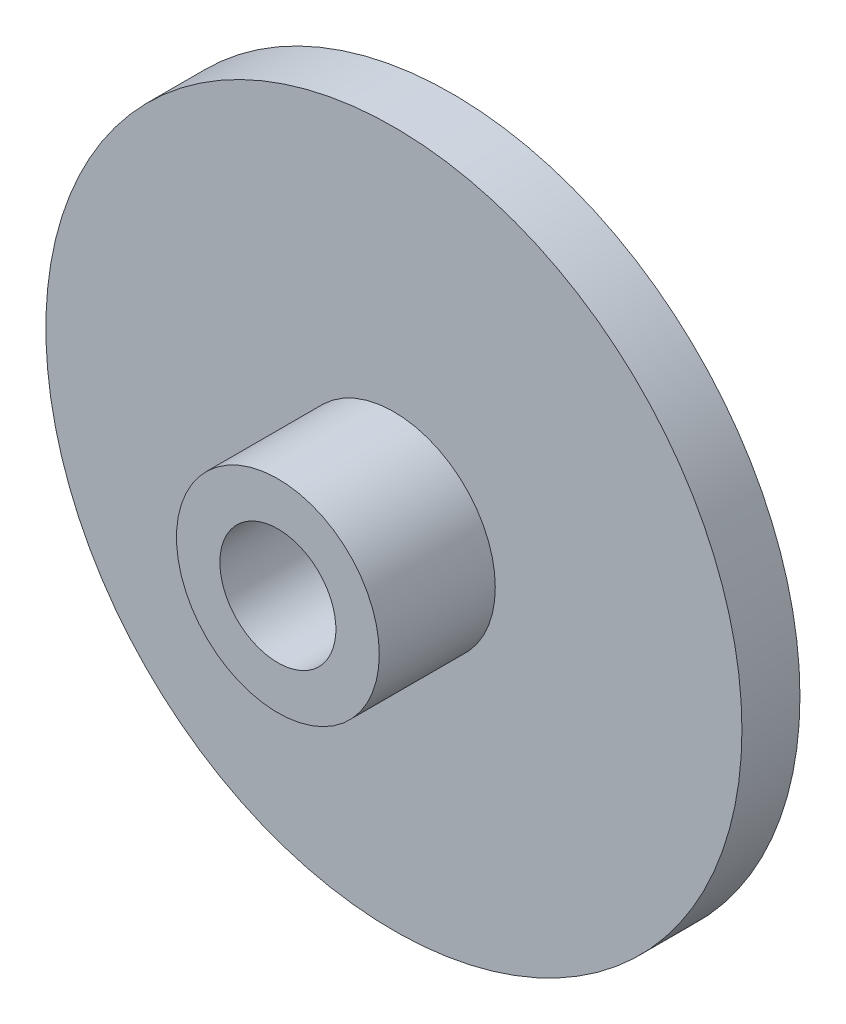
from build123d import *

# Parameters (mm, degrees)
SKETCH1_R           = 19.05
BOSS_EXTRUDE1_DEPTH = 3.175
SKETCH2_R           = 5.5499
BOSS_EXTRUDE2_DEPTH = 6.35
SKETCH3_R           = 3.175
CUT_EXTRUDE1_DEPTH  = 9.525


with BuildPart() as part:
    # Sketch1 → Boss-Extrude1 (new body)
    with BuildSketch(Plane.XY):
        Circle(SKETCH1_R)
    extrude(amount=BOSS_EXTRUDE1_DEPTH)

    # Sketch2 → Boss-Extrude2 (add)
    with BuildSketch(Plane.XY.offset(3.175)):
        Circle(SKETCH2_R)
    extrude(amount=BOSS_EXTRUDE2_DEPTH)

    # Sketch3 → Cut-Extrude1 (cut)
    with BuildSketch(Plane(origin=(0, 0, 0), x_dir=(-1, 0, 0), z_dir=(0, 0, -1))):
        Circle(SKETCH3_R)
    extrude(amount=-CUT_EXTRUDE1_DEPTH, mode=Mode.SUBTRACT)


solid = part.part
